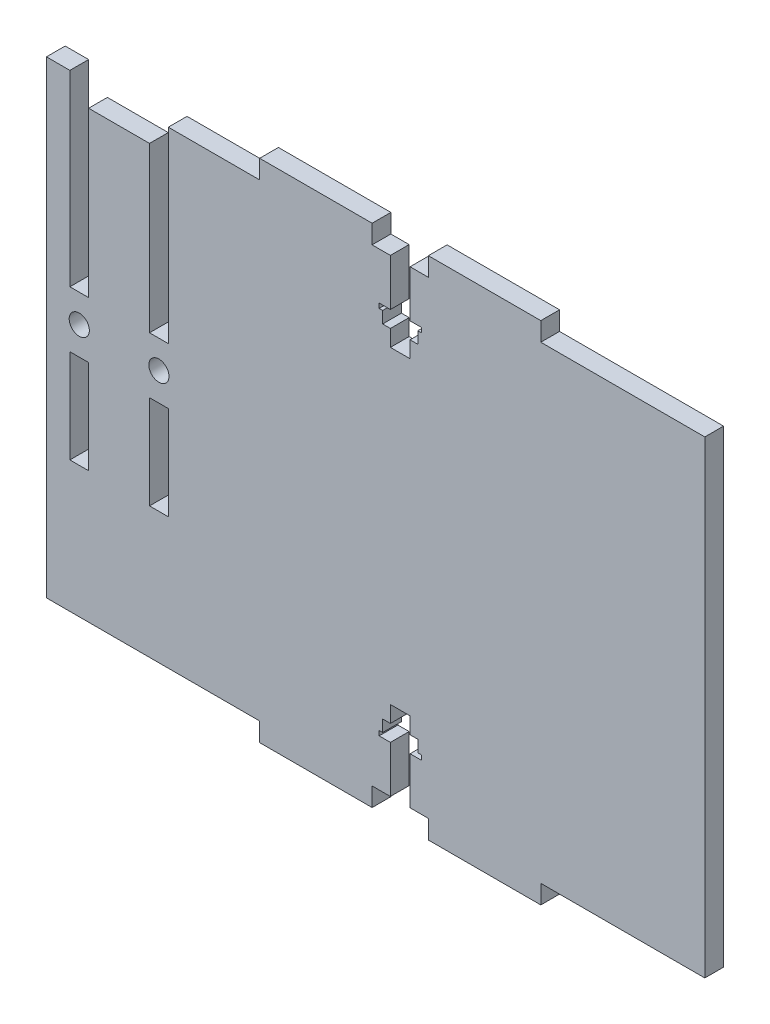
from build123d import *

# Parameters (mm, degrees)
SKETCH1_W                = 250
SKETCH1_H                = 100
BOSS_EXTRUDE1_DEPTH      = 4
SKETCH2_W                = 24
SKETCH2_H                = 4
BOSS_EXTRUDE2_DEPTH      = 4
SKETCH3_W                = 4
SKETCH3_H                = 40
SKETCH3_H_2              = 20
CUT_EXTRUDE1_DEPTH       = 5
M4_CLEARANCE_HOLE1_D     = 4.3
M4_CLEARANCE_HOLE1_DEPTH = 6
M4_CLEARANCE_HOLE1_TIP   = 1.291850331
CUT_EXTRUDE2_DEPTH       = 10
SKETCH7_W                = 13
SKETCH7_H                = 5
CUT_EXTRUDE3_DEPTH       = 10
CUT_EXTRUDE4_DEPTH       = 10


with BuildPart() as part:
    # Sketch1 → Boss-Extrude1 (new body)
    with BuildSketch(Plane.XY):
        Rectangle(SKETCH1_W, SKETCH1_H)
    extrude(amount=BOSS_EXTRUDE1_DEPTH)

    # Sketch2 → Boss-Extrude2 (add)
    with BuildSketch(Plane.XZ.offset(50)):
        with Locations((-78, 2)):
            Rectangle(SKETCH2_W, SKETCH2_H)
        with Locations((-42, 2)):
            Rectangle(SKETCH2_W, SKETCH2_H)
        with Locations((42, 2)):
            Rectangle(SKETCH2_W, SKETCH2_H)
        with Locations((78, 2)):
            Rectangle(SKETCH2_W, SKETCH2_H)
    boss_extrude2 = extrude(amount=BOSS_EXTRUDE2_DEPTH)

    # Sketch3 → Cut-Extrude1 (cut, through all)
    with BuildSketch(Plane.XY.offset(4)):
        with Locations((-8.5, 30)):
            Rectangle(SKETCH3_W, SKETCH3_H)
        with Locations((-8.5, -12)):
            Rectangle(SKETCH3_W, SKETCH3_H_2)
        with Locations((8.5, -12)):
            Rectangle(SKETCH3_W, SKETCH3_H_2)
        with Locations((8.5, 30)):
            Rectangle(SKETCH3_W, SKETCH3_H)
    extrude(amount=-CUT_EXTRUDE1_DEPTH, mode=Mode.SUBTRACT)

    # Mirror1: Boss-Extrude2 across plane
    add(boss_extrude2.mirror(Plane.ZX))

    # M4 Clearance Hole1
    with Locations(Plane.XY.offset(4)):
        with Locations((-8.5, 4), (8.5, 4)):
            Hole(M4_CLEARANCE_HOLE1_D / 2, depth=M4_CLEARANCE_HOLE1_DEPTH)
            with Locations((0, 0, -(M4_CLEARANCE_HOLE1_DEPTH + M4_CLEARANCE_HOLE1_TIP / 2))):  # 118° drill point
                Cone(0, M4_CLEARANCE_HOLE1_D / 2, M4_CLEARANCE_HOLE1_TIP, mode=Mode.SUBTRACT)

    # Sketch6 → Cut-Extrude2 (cut)
    with BuildSketch(Plane.XY.offset(4)):
        Polygon((-62.1, -50), (-57.9, -50), (-57.9, -40), (-55.5, -40), (-55.5, -39), (-56.25, -39), (-56.25, -36.5), (-57.9, -36.5), (-57.9, -33), (-62.1, -33), (-62.1, -36.5), (-63.75, -36.5), (-63.75, -39), (-64.5, -39), (-64.5, -40), (-62.1, -40), align=None)
        Polygon((57.9, -40), (57.9, -50), (62.1, -50), (62.1, -40), (64.5, -40), (64.5, -39), (63.75, -39), (63.75, -36.5), (62.1, -36.5), (62.1, -33), (57.9, -33), (57.9, -36.5), (56.25, -36.5), (56.25, -39), (55.5, -39), (55.5, -40), align=None)
        Polygon((62.1, 40), (62.1, 50), (57.9, 50), (57.9, 40), (55.5, 40), (55.5, 39), (56.25, 39), (56.25, 36.5), (57.9, 36.5), (57.9, 33), (62.1, 33), (62.1, 36.5), (63.75, 36.5), (63.75, 39), (64.5, 39), (64.5, 40), align=None)
        Polygon((-57.9, 50), (-62.1, 50), (-62.1, 40), (-64.5, 40), (-64.5, 39), (-63.75, 39), (-63.75, 36.5), (-62.1, 36.5), (-62.1, 33), (-57.9, 33), (-57.9, 36.5), (-56.25, 36.5), (-56.25, 39), (-55.5, 39), (-55.5, 40), (-57.9, 40), align=None)
    extrude(amount=-CUT_EXTRUDE2_DEPTH, mode=Mode.SUBTRACT)

    # Sketch7 → Cut-Extrude3 (cut)
    with BuildSketch(Plane.XY.offset(4)):
        with Locations((0, 47.5)):
            Rectangle(SKETCH7_W, SKETCH7_H)
    extrude(amount=-CUT_EXTRUDE3_DEPTH, mode=Mode.SUBTRACT)

    # Sketch8 → Cut-Extrude4 (cut)
    with BuildSketch(Plane.XY.offset(4)):
        Polygon((-15.5, 50), (-32.700401322, 262.698056725), (-161.835837728, 81.113354009), (-171.999440278, -88.149719236), (-15.5, -103.395123062), align=None)
    extrude(amount=-CUT_EXTRUDE4_DEPTH, mode=Mode.SUBTRACT)


solid = part.part
